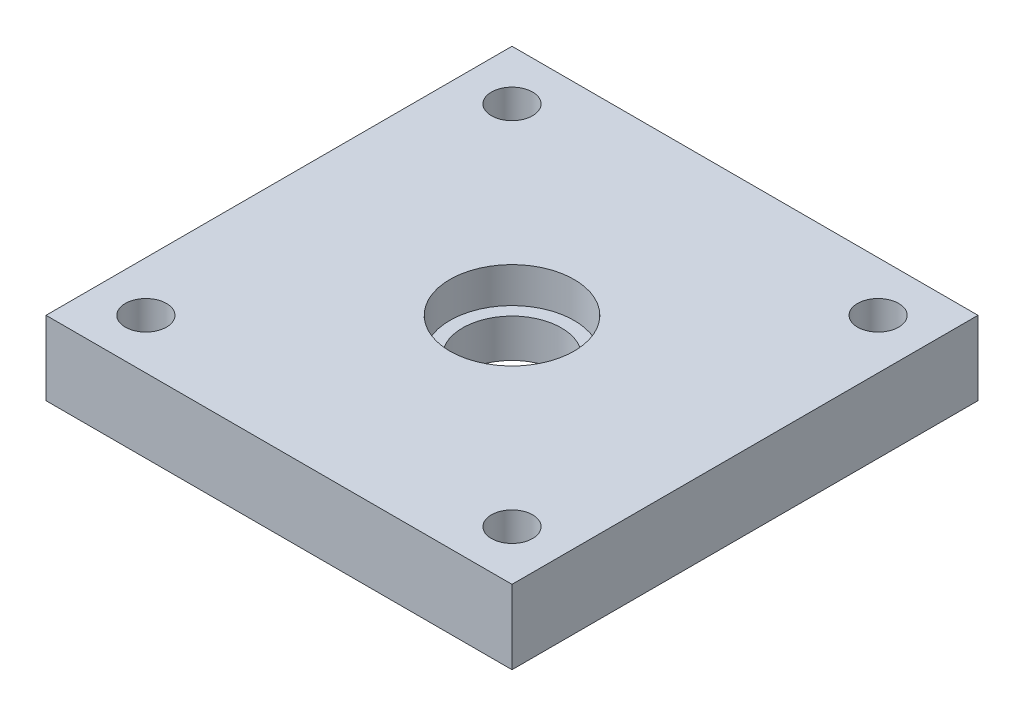
from build123d import *

# Parameters (mm, degrees)
SKETCH1_W            = 60
SKETCH1_H            = 60
BOSS_EXTRUDE1_DEPTH  = 9.525
M5_CLEARANCE_HOLE1_D = 5.3
SKETCH5_R            = 8
CUT_EXTRUDE1_DEPTH   = 4.572
SKETCH6_R            = 6.35
CUT_EXTRUDE2_DEPTH   = 5.953


with BuildPart() as part:
    # Sketch1 → Boss-Extrude1 (new body)
    with BuildSketch(Plane(origin=(0, 0, 0), x_dir=(1, 0, 0), z_dir=(0, 1, 0))):
        Rectangle(SKETCH1_W, SKETCH1_H)
    extrude(amount=BOSS_EXTRUDE1_DEPTH)

    # M5 Clearance Hole1 (through all)
    with Locations(Plane(origin=(0, 9.525, 0), x_dir=(1, 0, 0), z_dir=(0, 1, 0))):
        with Locations((-23.57, 23.57), (23.57, 23.57), (23.57, -23.57), (-23.57, -23.57)):
            Hole(M5_CLEARANCE_HOLE1_D / 2)

    # Sketch5 → Cut-Extrude1 (cut)
    with BuildSketch(Plane(origin=(0, 9.525, 0), x_dir=(1, 0, 0), z_dir=(0, 1, 0))):
        Circle(SKETCH5_R)
    extrude(amount=-CUT_EXTRUDE1_DEPTH, mode=Mode.SUBTRACT)

    # Sketch6 → Cut-Extrude2 (cut, through all)
    with BuildSketch(Plane(origin=(0, 4.953, 0), x_dir=(1, 0, 0), z_dir=(0, 1, 0))):
        Circle(SKETCH6_R)
    extrude(amount=-CUT_EXTRUDE2_DEPTH, mode=Mode.SUBTRACT)


solid = part.part
